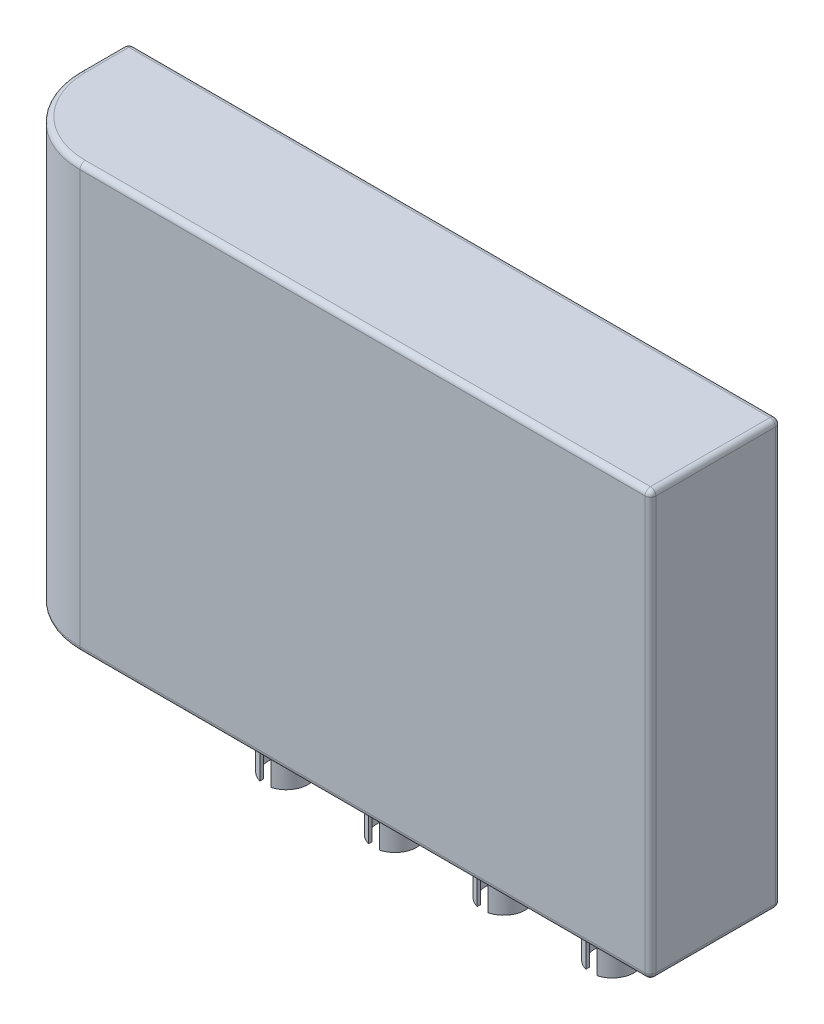
from build123d import *

# Parameters (mm, degrees)
SKETCH1_W           = 120
SKETCH1_H           = 78
BOSS_EXTRUDE1_DEPTH = 24
FILLET1_R           = 15
FILLET2_R           = 1
BOSS_EXTRUDE2_DEPTH = 8
SKETCH2_3_R         = 4
CUT_EXTRUDE1_DEPTH  = 8


with BuildPart() as part:
    # Sketch1 → Boss-Extrude1 (new body)
    with BuildSketch(Plane.XY):
        Rectangle(SKETCH1_W, SKETCH1_H)
    extrude(amount=BOSS_EXTRUDE1_DEPTH)

    # Fillet1
    fillet1_edges = [part.edges().sort_by_distance(p)[0] for p in [
        (-60, 0, 24),
    ]]
    fillet(fillet1_edges, radius=FILLET1_R)

    # Fillet2
    fillet2_edges = [part.edges().sort_by_distance(p)[0] for p in [
        (-60, 39, 4.5),
        (7.5, 39, 24),
        (-55.606601718, 39, 19.606601718),
        (-60, -39, 4.5),
        (-55.606601718, -39, 19.606601718),
        (7.5, -39, 24),
        (0, 39, 0),
        (-60, 0, 0),
        (0, -39, 0),
        (60, -39, 12),
        (60, 0, 24),
        (60, 39, 12),
        (60, 0, 0),
    ]]
    fillet(fillet2_edges, radius=FILLET2_R)

    # Sketch2 → Boss-Extrude2 (add)
    with BuildSketch(Plane(origin=(0, -39, 0), x_dir=(-1, 0, 0), z_dir=(0, -1, 0))):
        with BuildLine():
            Line((16, -19.249615362), (16, -19.872983346))
            ThreePointArc((16, -19.872983346), (15, -12), (14, -19.872983346))
            Line((14, -19.872983346), (14, -19.249615362))
            ThreePointArc((14, -19.249615362), (15, -12.6), (16, -19.249615362))
        make_face()
        with BuildLine():
            ThreePointArc((-4, -19.872983346), (-5, -12), (-6, -19.872983346))
            Line((-6, -19.872983346), (-6, -19.249615362))
            ThreePointArc((-6, -19.249615362), (-5, -12.6), (-4, -19.249615362))
            Line((-4, -19.249615362), (-4, -19.872983346))
        make_face()
        with BuildLine():
            ThreePointArc((-24, -19.872983346), (-25, -12), (-26, -19.872983346))
            Line((-26, -19.872983346), (-26, -19.249615362))
            ThreePointArc((-26, -19.249615362), (-25, -12.6), (-24, -19.249615362))
            Line((-24, -19.249615362), (-24, -19.872983346))
        make_face()
        with BuildLine():
            ThreePointArc((-44, -19.872983346), (-45, -12), (-46, -19.872983346))
            Line((-46, -19.872983346), (-46, -19.249615362))
            ThreePointArc((-46, -19.249615362), (-45, -12.6), (-44, -19.249615362))
            Line((-44, -19.249615362), (-44, -19.872983346))
        make_face()
    extrude(amount=BOSS_EXTRUDE2_DEPTH)

    # Sketch2_3 → Cut-Extrude1 (cut)
    with BuildSketch(Plane(origin=(0, -39, 0), x_dir=(-1, 0, 0), z_dir=(0, -1, 0))):
        with Locations((35, -16)):
            Circle(SKETCH2_3_R)
    extrude(amount=-CUT_EXTRUDE1_DEPTH, mode=Mode.SUBTRACT)


solid = part.part
